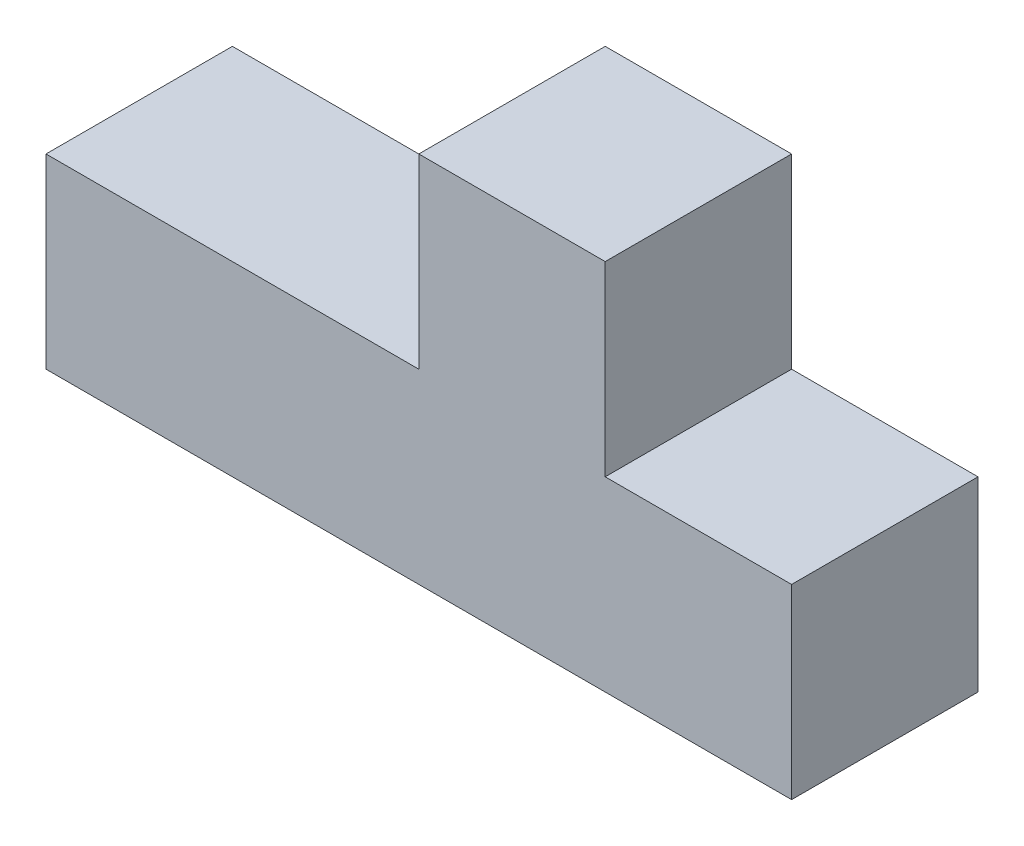
from build123d import *

# Parameters (mm, degrees)
BOSS_EXTRUDE1_DEPTH = 25.4


with BuildPart() as part:
    # Sketch1 → Boss-Extrude1 (new body)
    with BuildSketch(Plane.XY):
        Polygon((0, 0), (101.6, 0), (101.6, 25.4), (76.2, 25.4), (76.2, 50.8), (50.8, 50.8), (50.8, 25.4), (0, 25.4), align=None)
    extrude(amount=BOSS_EXTRUDE1_DEPTH)


solid = part.part
